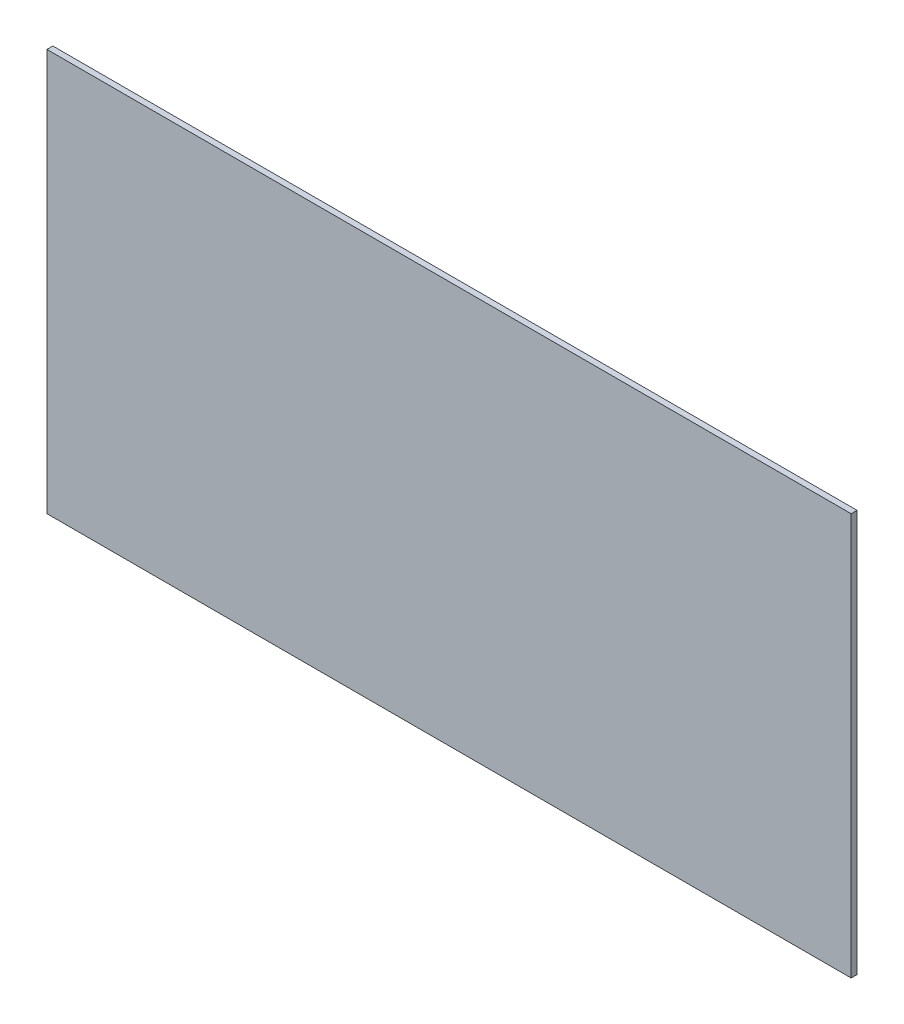
from build123d import *

# Parameters (mm, degrees)
SKETCH1_W           = 863.6
SKETCH1_H           = 431.8
BOSS_EXTRUDE1_DEPTH = 6.35


with BuildPart() as part:
    # Sketch1 → Boss-Extrude1 (new body)
    with BuildSketch(Plane.XY):
        with Locations((431.8, 215.9)):
            Rectangle(SKETCH1_W, SKETCH1_H)
    extrude(amount=BOSS_EXTRUDE1_DEPTH)


solid = part.part
